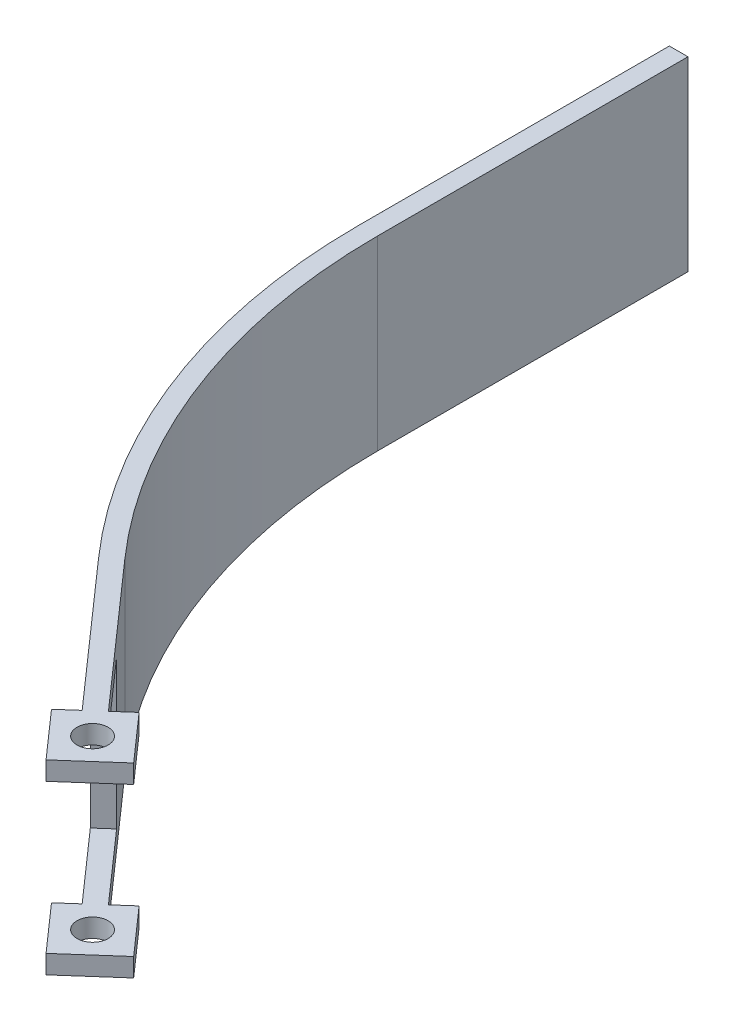
from build123d import *

# Parameters (mm, degrees)
ESQUISSE1_R      = 2.5
EXTRUSION1_DEPTH = 30
ESQUISSE3_W      = 25
ESQUISSE3_H      = 24
EXTRUSION2_DEPTH = 105.777068413


with BuildPart() as part:
    # Esquisse1 → Extrusion1 (new body)
    with BuildSketch(Plane(origin=(0, 0, 0), x_dir=(1, 0, 0), z_dir=(0, 1, 0))):
        with BuildLine():
            Line((0, 0), (0, 50))
            Line((0, 50), (3, 50))
            Line((3, 50), (3, 0))
            ThreePointArc((3, 0), (9.404287474, -35.029045403), (27.788566098, -65.526048852))
            Line((27.788566098, -65.526048852), (47.644944538, -88.014362156))
            Line((47.644944538, -88.014362156), (50.26858109, -85.697784671))
            Line((50.26858109, -85.697784671), (56.887373903, -93.193889106))
            Line((56.887373903, -93.193889106), (49.391269469, -99.812681919))
            Line((49.391269469, -99.812681919), (42.772476656, -92.316577485))
            Line((42.772476656, -92.316577485), (45.396113208, -90))
            Line((45.396113208, -90), (25.539734768, -67.511686696))
            ThreePointArc((25.539734768, -67.511686696), (6.598356792, -36.090531627), (0, 0))
        make_face()
        with Locations((49.82992528, -92.755233295)):
            Circle(ESQUISSE1_R, mode=Mode.SUBTRACT)
    extrude(amount=EXTRUSION1_DEPTH)

    # Esquisse3 → Extrusion2 (cut, through all)
    with BuildSketch(Plane(origin=(-21.768488457, 0, 19.220798778), x_dir=(0.661879281, 0, 0.749610443), z_dir=(-0.749610443, 0, 0.661879281))):
        with Locations((95.011686696, 15)):
            Rectangle(ESQUISSE3_W, ESQUISSE3_H)
    extrude(amount=-EXTRUSION2_DEPTH, mode=Mode.SUBTRACT)


solid = part.part
